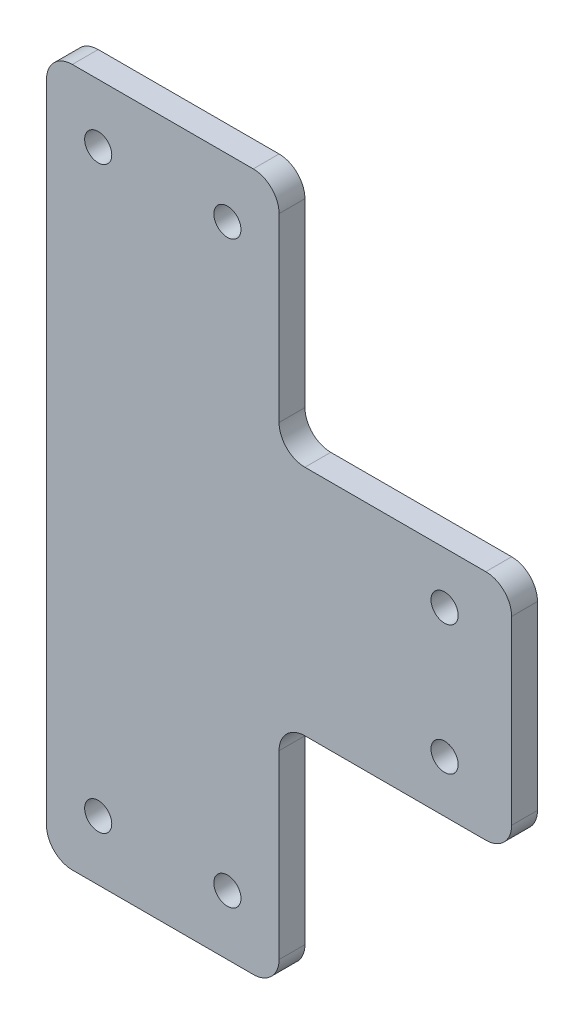
from build123d import *

# Parameters (mm, degrees)
BOSS_EXTRUDE1_DEPTH   = 4
M5X0_8_TAPPED_HOLE1_D = 4.2
FILLET1_R             = 4


with BuildPart() as part:
    # Sketch1 → Boss-Extrude1 (new body)
    with BuildSketch(Plane.XY):
        Polygon((0, -18), (0, -54), (-36, -54), (-36, 54), (0, 54), (0, 18), (36, 18), (36, -18), align=None)
    extrude(amount=BOSS_EXTRUDE1_DEPTH)

    # M5x0.8 Tapped Hole1 (through all)
    with Locations(Plane.XY.offset(4)):
        with Locations((-28, 44.91241041), (-8, 44.91241041), (25.616827634, 10), (25.616827634, -10), (-28, -44.758024198), (-8, -44.758024198)):
            Hole(M5X0_8_TAPPED_HOLE1_D / 2)

    # Fillet1
    fillet1_edges = [part.edges().sort_by_distance(p)[0] for p in [
        (-36, 54, 2),
        (0, 54, 2),
        (0, 18, 2),
        (36, 18, 2),
        (36, -18, 2),
        (0, -18, 2),
        (0, -54, 2),
        (-36, -54, 2),
    ]]
    fillet(fillet1_edges, radius=FILLET1_R)


solid = part.part
